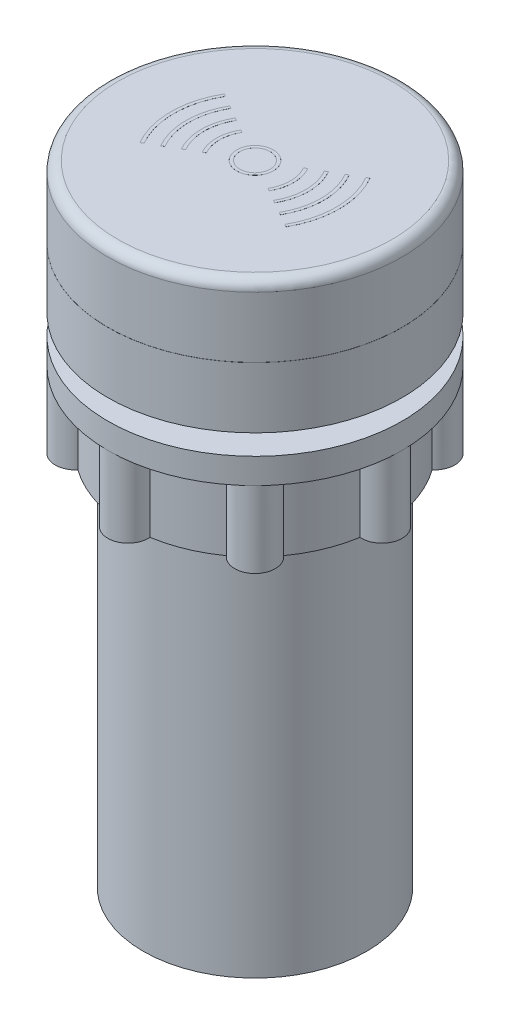
from build123d import *

# Parameters (mm, degrees)
SKETCH2_R           = 2
BOSS_EXTRUDE1_DEPTH = 7.5
CIRPATTERN1_COUNT   = 8
SKETCH3_R           = 1.8
SKETCH3_R_2         = 1.5
BOSS_EXTRUDE2_DEPTH = 0.005


with BuildPart() as part:
    # Sketch1 → Revolve1 (revolve)
    with BuildSketch(Plane.XY):
        with BuildLine():
            Line((0, 0), (0, 62))
            Line((0, 62), (13.5, 62))
            ThreePointArc((13.5, 62), (14.207106781, 61.707106781), (14.5, 61))
            Line((14.5, 61), (14.5, 55.005))
            Line((14.5, 55.005), (11, 55.005))
            Line((11, 55.005), (11, 54.995))
            Line((11, 54.995), (14.5, 54.995))
            Line((14.5, 54.995), (14.5, 49))
            Line((14.5, 49), (11, 49))
            Line((11, 49), (11, 47))
            Line((11, 47), (14.5, 47))
            Line((14.5, 47), (14.5, 44.5))
            Line((14.5, 44.5), (12.5, 44.5))
            Line((12.5, 44.5), (12.5, 37))
            Line((12.5, 37), (11, 37))
            Line((11, 37), (11, 0))
            Line((11, 0), (0, 0))
        make_face()
    revolve(axis=Axis((0, 0, 0), (0, -1, 0)))

    # Sketch2 → Boss-Extrude1 (add)
    with BuildSketch(Plane.XZ.offset(-44.5)):
        with Locations((0, 12.5)):
            Circle(SKETCH2_R)
    boss_extrude1 = extrude(amount=BOSS_EXTRUDE1_DEPTH)

    # CirPattern1: Boss-Extrude1 ×8 about axis
    cirpattern1_axis = Axis((0, 0, 0), (0, 1, 0))
    for i in range(1, CIRPATTERN1_COUNT):
        add(boss_extrude1.rotate(cirpattern1_axis, i * 360 / CIRPATTERN1_COUNT))

    # Sketch3 → Boss-Extrude2 (add)
    with BuildSketch(Plane(origin=(0, 62, 0), x_dir=(1, 0, 0), z_dir=(0, 1, 0))):
        Circle(SKETCH3_R)
        Circle(SKETCH3_R_2, mode=Mode.SUBTRACT)
        with BuildLine():
            Line((-4.330127019, -2.5), (-4.58993464, -2.65))
            ThreePointArc((-4.58993464, -2.65), (-5.3, 0), (-4.58993464, 2.65))
            Line((-4.58993464, 2.65), (-4.330127019, 2.5))
            ThreePointArc((-4.330127019, 2.5), (-5, 0), (-4.330127019, -2.5))
        make_face()
        with BuildLine():
            Line((-3.031088913, -1.75), (-3.290896534, -1.9))
            ThreePointArc((-3.290896534, -1.9), (-3.8, 0), (-3.290896534, 1.9))
            Line((-3.290896534, 1.9), (-3.031088913, 1.75))
            ThreePointArc((-3.031088913, 1.75), (-3.5, 0), (-3.031088913, -1.75))
        make_face()
        with BuildLine():
            Line((-5.629165125, -3.25), (-5.888972746, -3.4))
            ThreePointArc((-5.888972746, -3.4), (-6.8, 0), (-5.888972746, 3.4))
            Line((-5.888972746, 3.4), (-5.629165125, 3.25))
            ThreePointArc((-5.629165125, 3.25), (-6.5, 0), (-5.629165125, -3.25))
        make_face()
        with BuildLine():
            Line((-6.92820323, -4), (-7.188010851, -4.15))
            ThreePointArc((-7.188010851, -4.15), (-8.3, 0), (-7.188010851, 4.15))
            Line((-7.188010851, 4.15), (-6.92820323, 4))
            ThreePointArc((-6.92820323, 4), (-8, 0), (-6.92820323, -4))
        make_face()
        with BuildLine():
            Line((6.92820323, 4), (7.188010851, 4.15))
            ThreePointArc((7.188010851, 4.15), (8.3, 0), (7.188010851, -4.15))
            Line((7.188010851, -4.15), (6.92820323, -4))
            ThreePointArc((6.92820323, -4), (8, 0), (6.92820323, 4))
        make_face()
        with BuildLine():
            Line((5.629165125, 3.25), (5.888972746, 3.4))
            ThreePointArc((5.888972746, 3.4), (6.8, 0), (5.888972746, -3.4))
            Line((5.888972746, -3.4), (5.629165125, -3.25))
            ThreePointArc((5.629165125, -3.25), (6.5, 0), (5.629165125, 3.25))
        make_face()
        with BuildLine():
            Line((4.330127019, 2.5), (4.58993464, 2.65))
            ThreePointArc((4.58993464, 2.65), (5.3, 0), (4.58993464, -2.65))
            Line((4.58993464, -2.65), (4.330127019, -2.5))
            ThreePointArc((4.330127019, -2.5), (5, 0), (4.330127019, 2.5))
        make_face()
        with BuildLine():
            Line((3.031088913, 1.75), (3.290896534, 1.9))
            ThreePointArc((3.290896534, 1.9), (3.8, 0), (3.290896534, -1.9))
            Line((3.290896534, -1.9), (3.031088913, -1.75))
            ThreePointArc((3.031088913, -1.75), (3.5, 0), (3.031088913, 1.75))
        make_face()
    extrude(amount=BOSS_EXTRUDE2_DEPTH)


solid = part.part
